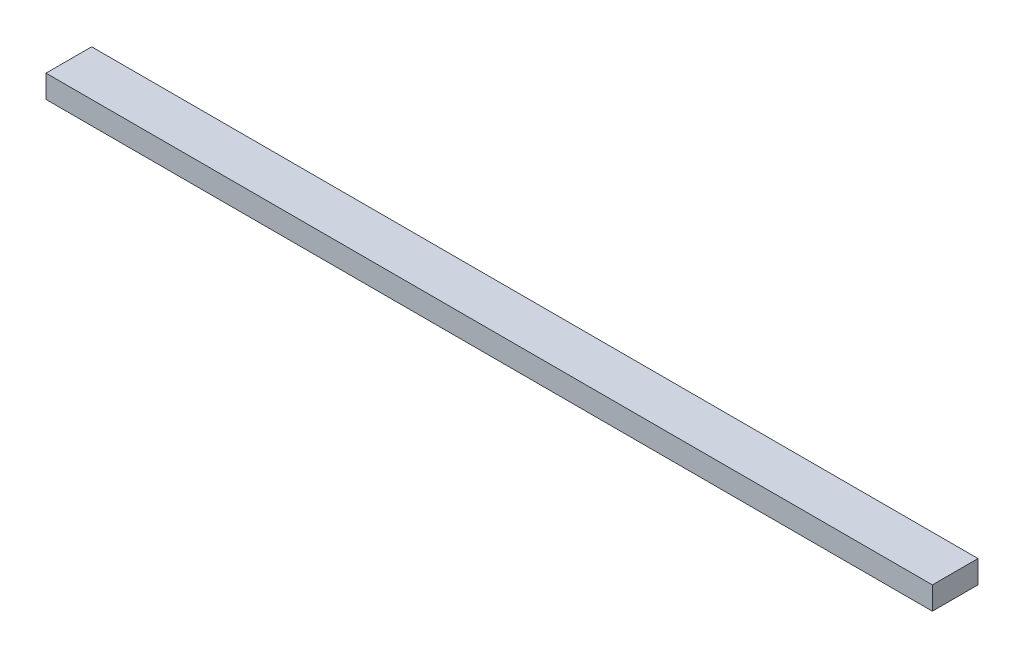
from build123d import *

# Parameters (mm, degrees)
SKETCH1_W           = 38.1
SKETCH1_H           = 19.05
BOSS_EXTRUDE1_DEPTH = 740


with BuildPart() as part:
    # Sketch1 → Boss-Extrude1 (new body)
    with BuildSketch(Plane(origin=(0, 0, 0), x_dir=(0, 0, -1), z_dir=(1, 0, 0))):
        with Locations((19.05, 9.525)):
            Rectangle(SKETCH1_W, SKETCH1_H)
    extrude(amount=BOSS_EXTRUDE1_DEPTH)


solid = part.part
